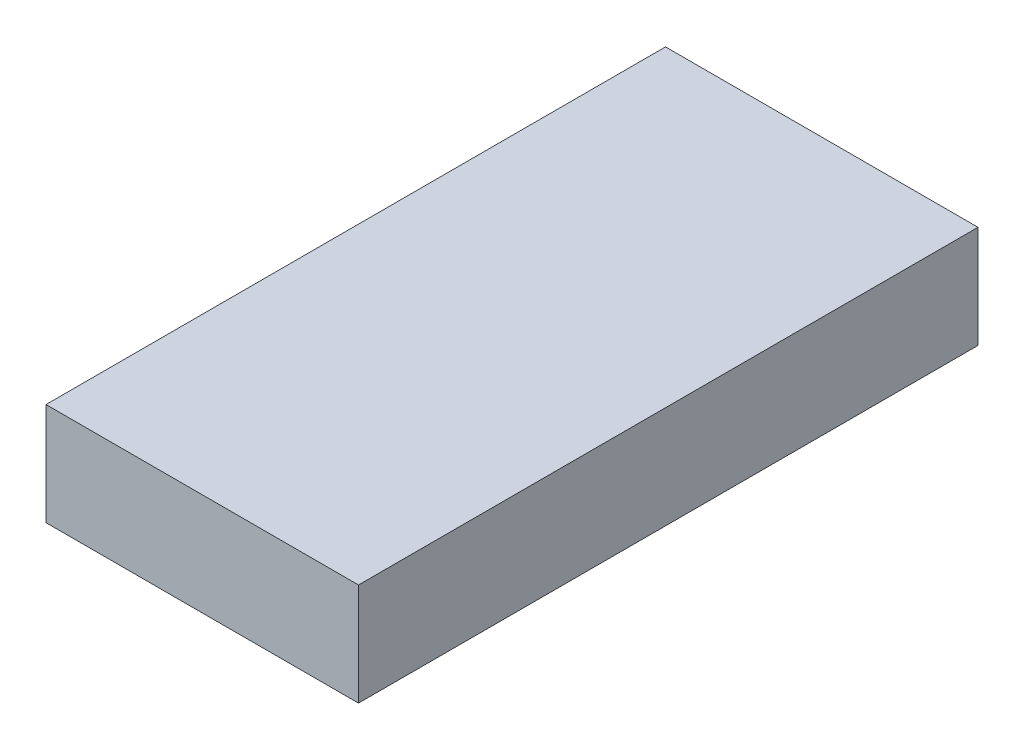
from build123d import *

# Parameters (mm, degrees)
SKETCH_1_W      = 34.2
SKETCH_1_H      = 67.8
EXTRUDE_1_DEPTH = 11.2


with BuildPart() as part:
    # 草图1 → 凸台-拉伸1 (new body)
    with BuildSketch(Plane(origin=(0, 0, 0), x_dir=(1, 0, 0), z_dir=(0, 1, 0))):
        Rectangle(SKETCH_1_W, SKETCH_1_H)
    extrude(amount=EXTRUDE_1_DEPTH)


solid = part.part
